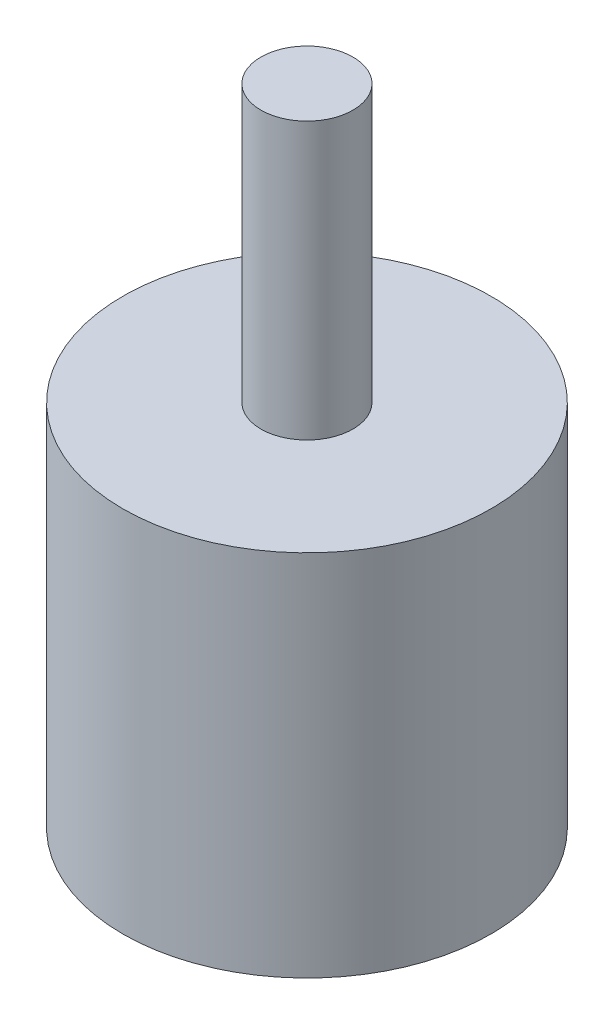
from build123d import *

# Parameters (mm, degrees)
SKETCH1_R           = 12.7
BOSS_EXTRUDE1_DEPTH = 25.4
SKETCH2_R           = 3.175
BOSS_EXTRUDE2_DEPTH = 19.05


with BuildPart() as part:
    # Sketch1 → Boss-Extrude1 (new body)
    with BuildSketch(Plane(origin=(0, 0, 0), x_dir=(1, 0, 0), z_dir=(0, 1, 0))):
        Circle(SKETCH1_R)
    extrude(amount=BOSS_EXTRUDE1_DEPTH)

    # Sketch2 → Boss-Extrude2 (add)
    with BuildSketch(Plane(origin=(0, 25.4, 0), x_dir=(1, 0, 0), z_dir=(0, 1, 0))):
        Circle(SKETCH2_R)
    extrude(amount=BOSS_EXTRUDE2_DEPTH)


solid = part.part
